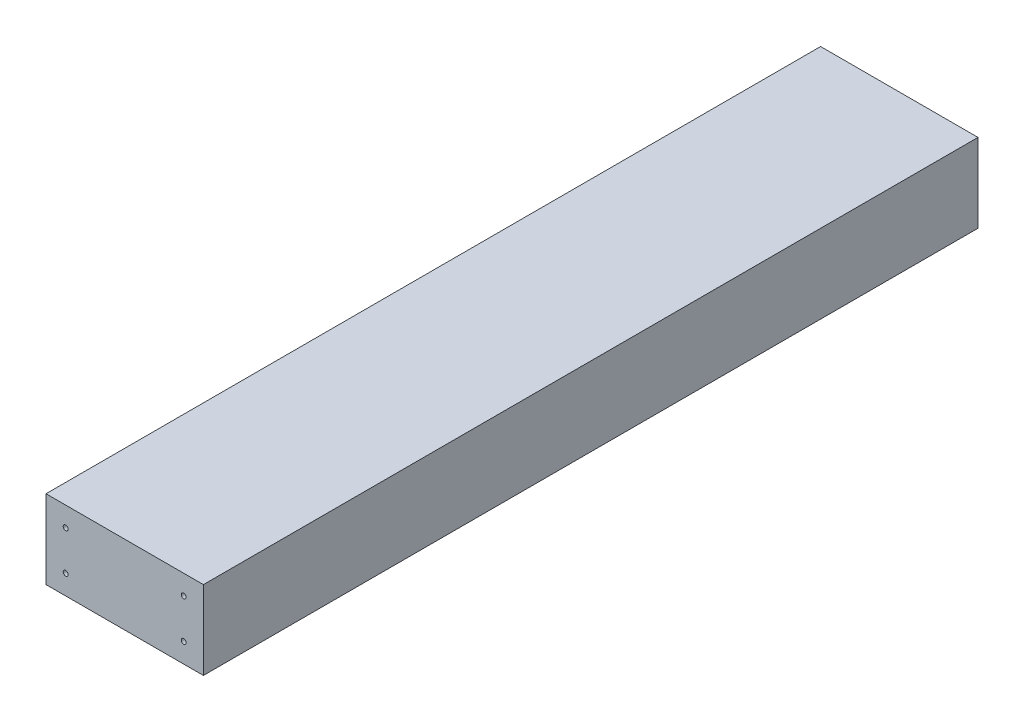
from build123d import *

# Parameters (mm, degrees)
SKETCH1_W           = 101.6
SKETCH1_H           = 50.8
BOSS_EXTRUDE1_DEPTH = 500
SKETCH2_R           = 1.5875
CUT_EXTRUDE1_DEPTH  = 44.45


with BuildPart() as part:
    # Sketch1 → Boss-Extrude1 (new body)
    with BuildSketch(Plane.XY):
        Rectangle(SKETCH1_W, SKETCH1_H)
    extrude(amount=BOSS_EXTRUDE1_DEPTH)

    # Sketch2 → Cut-Extrude1 (cut)
    with BuildSketch(Plane.XY.offset(500)):
        with Locations((-38.1, 12.7)):
            Circle(SKETCH2_R)
        with Locations((38.1, 12.7)):
            Circle(SKETCH2_R)
        with Locations((38.1, -12.7)):
            Circle(SKETCH2_R)
        with Locations((-38.1, -12.7)):
            Circle(SKETCH2_R)
    cut_extrude1 = extrude(amount=-CUT_EXTRUDE1_DEPTH, mode=Mode.SUBTRACT)

    # Mirror1: Cut-Extrude1 across plane
    add(cut_extrude1.mirror(Plane(origin=(0, 0, 250), x_dir=(1, 0, 0), z_dir=(0, 0, -1))), mode=Mode.SUBTRACT)


solid = part.part
